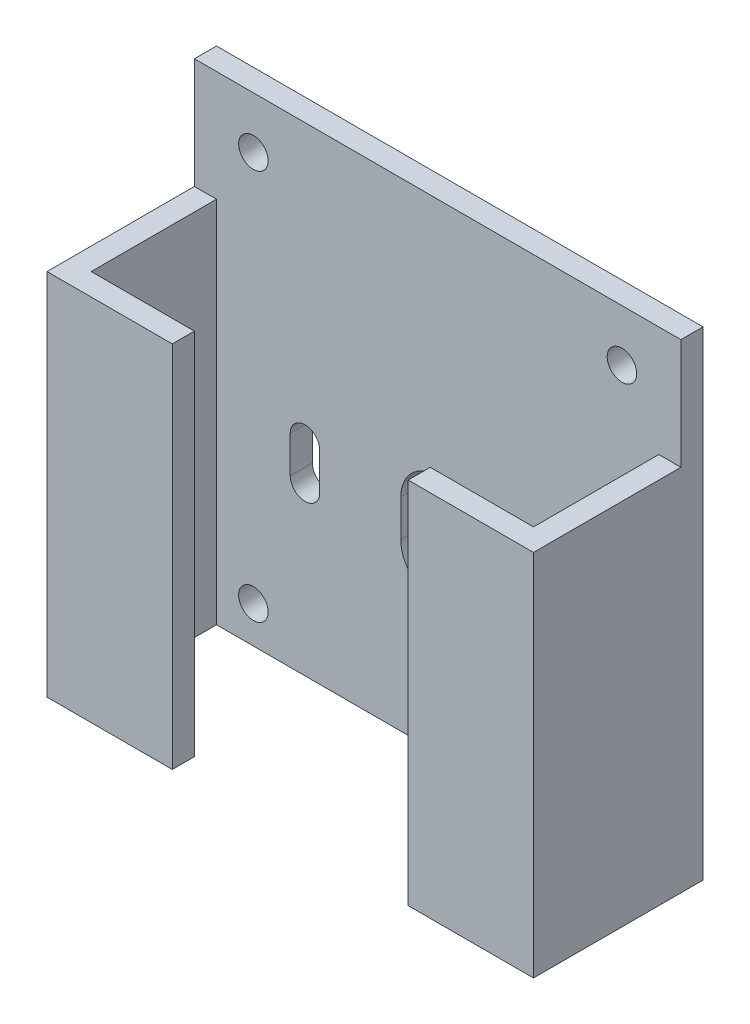
from build123d import *

# Parameters (mm, degrees)
SKETCH1_W           = 23
SKETCH1_H           = 65
BOSS_EXTRUDE1_DEPTH = 66
SKETCH2_W           = 60
SKETCH2_H           = 17
CUT_EXTRUDE1_DEPTH  = 66
CUT_EXTRUDE2_REACH  = 25
SKETCH3_W           = 32
SKETCH3_H           = 65
CUT_EXTRUDE3_REACH  = 25
SKETCH5_R           = 2
SKETCH6_W           = 17
SKETCH6_H           = 15
CUT_EXTRUDE4_DEPTH  = 20


with BuildPart() as part:
    # Sketch1 → Boss-Extrude1 (new body)
    with BuildSketch(Plane(origin=(0, 0, 0), x_dir=(0, 0, -1), z_dir=(1, 0, 0))):
        with Locations((-11.5, -32.5)):
            Rectangle(SKETCH1_W, SKETCH1_H)
    extrude(amount=-BOSS_EXTRUDE1_DEPTH)

    # Sketch2 → Cut-Extrude1 (cut, through all)
    with BuildSketch(Plane(origin=(0, 0, 0), x_dir=(1, 0, 0), z_dir=(0, 1, 0))):
        with Locations((-33, -11.5)):
            Rectangle(SKETCH2_W, SKETCH2_H)
    extrude(amount=-CUT_EXTRUDE1_DEPTH, mode=Mode.SUBTRACT)

    # Sketch3 → Cut-Extrude2 (cut, up to next)
    with BuildSketch(Plane.XY.offset(23), mode=Mode.PRIVATE) as cut_extrude2_sk1:
        with Locations((-33, -32.5)):
            Rectangle(SKETCH3_W, SKETCH3_H)
    cut_extrude2_tool1 = extrude(cut_extrude2_sk1.sketch, amount=-CUT_EXTRUDE2_REACH, mode=Mode.PRIVATE) & part.part
    add(cut_extrude2_tool1.solids().sort_by_distance((-33, -32.5, 23))[0], mode=Mode.SUBTRACT)

    # Sketch5 → Cut-Extrude3 (cut, up to next)
    with BuildSketch(Plane(origin=(0, 0, 0), x_dir=(-1, 0, 0), z_dir=(0, 0, -1)), mode=Mode.PRIVATE) as cut_extrude3_sk1:
        with Locations((8, -7)):
            Circle(SKETCH5_R)
    cut_extrude3_tool1 = extrude(cut_extrude3_sk1.sketch, amount=-CUT_EXTRUDE3_REACH, mode=Mode.PRIVATE) & part.part
    add(cut_extrude3_tool1.solids().sort_by_distance((-8, -7, 0))[0], mode=Mode.SUBTRACT)
    # Sketch5 → Cut-Extrude3 (cut, up to next)
    with BuildSketch(Plane(origin=(0, 0, 0), x_dir=(-1, 0, 0), z_dir=(0, 0, -1)), mode=Mode.PRIVATE) as cut_extrude3_sk2:
        with Locations((58, -7)):
            Circle(SKETCH5_R)
    cut_extrude3_tool2 = extrude(cut_extrude3_sk2.sketch, amount=-CUT_EXTRUDE3_REACH, mode=Mode.PRIVATE) & part.part
    add(cut_extrude3_tool2.solids().sort_by_distance((-58, -7, 0))[0], mode=Mode.SUBTRACT)
    # Sketch5 → Cut-Extrude3 (cut, up to next)
    with BuildSketch(Plane(origin=(0, 0, 0), x_dir=(-1, 0, 0), z_dir=(0, 0, -1)), mode=Mode.PRIVATE) as cut_extrude3_sk3:
        with Locations((8, -60)):
            Circle(SKETCH5_R)
    cut_extrude3_tool3 = extrude(cut_extrude3_sk3.sketch, amount=-CUT_EXTRUDE3_REACH, mode=Mode.PRIVATE) & part.part
    add(cut_extrude3_tool3.solids().sort_by_distance((-8, -60, 0))[0], mode=Mode.SUBTRACT)
    # Sketch5 → Cut-Extrude3 (cut, up to next)
    with BuildSketch(Plane(origin=(0, 0, 0), x_dir=(-1, 0, 0), z_dir=(0, 0, -1)), mode=Mode.PRIVATE) as cut_extrude3_sk4:
        with Locations((58, -60)):
            Circle(SKETCH5_R)
    cut_extrude3_tool4 = extrude(cut_extrude3_sk4.sketch, amount=-CUT_EXTRUDE3_REACH, mode=Mode.PRIVATE) & part.part
    add(cut_extrude3_tool4.solids().sort_by_distance((-58, -60, 0))[0], mode=Mode.SUBTRACT)
    # Sketch5 → Cut-Extrude3 (cut, up to next)
    with BuildSketch(Plane(origin=(0, 0, 0), x_dir=(-1, 0, 0), z_dir=(0, 0, -1)), mode=Mode.PRIVATE) as cut_extrude3_sk5:
        with BuildLine():
            Line((38, -37.5), (38, -42.5))
            ThreePointArc((38, -42.5), (33, -47.5), (28, -42.5))
            Line((28, -42.5), (28, -37.5))
            ThreePointArc((28, -37.5), (33, -32.5), (38, -37.5))
        make_face()
    cut_extrude3_tool5 = extrude(cut_extrude3_sk5.sketch, amount=-CUT_EXTRUDE3_REACH, mode=Mode.PRIVATE) & part.part
    add(cut_extrude3_tool5.solids().sort_by_distance((-33, -40, 0))[0], mode=Mode.SUBTRACT)
    # Sketch5 → Cut-Extrude3 (cut, up to next)
    with BuildSketch(Plane(origin=(0, 0, 0), x_dir=(-1, 0, 0), z_dir=(0, 0, -1)), mode=Mode.PRIVATE) as cut_extrude3_sk6:
        with BuildLine():
            Line((17, -37.5), (17, -42.5))
            ThreePointArc((17, -42.5), (15, -44.5), (13, -42.5))
            Line((13, -42.5), (13, -37.5))
            ThreePointArc((13, -37.5), (15, -35.5), (17, -37.5))
        make_face()
    cut_extrude3_tool6 = extrude(cut_extrude3_sk6.sketch, amount=-CUT_EXTRUDE3_REACH, mode=Mode.PRIVATE) & part.part
    add(cut_extrude3_tool6.solids().sort_by_distance((-15, -40, 0))[0], mode=Mode.SUBTRACT)
    # Sketch5 → Cut-Extrude3 (cut, up to next)
    with BuildSketch(Plane(origin=(0, 0, 0), x_dir=(-1, 0, 0), z_dir=(0, 0, -1)), mode=Mode.PRIVATE) as cut_extrude3_sk7:
        with BuildLine():
            Line((53, -37.5), (53, -42.5))
            ThreePointArc((53, -42.5), (51, -44.5), (49, -42.5))
            Line((49, -42.5), (49, -37.5))
            ThreePointArc((49, -37.5), (51, -35.5), (53, -37.5))
        make_face()
    cut_extrude3_tool7 = extrude(cut_extrude3_sk7.sketch, amount=-CUT_EXTRUDE3_REACH, mode=Mode.PRIVATE) & part.part
    add(cut_extrude3_tool7.solids().sort_by_distance((-51, -40, 0))[0], mode=Mode.SUBTRACT)

    # Sketch6 → Cut-Extrude4 (cut)
    with BuildSketch(Plane.XY.offset(23)):
        with Locations((-57.5, -7.5)):
            Rectangle(SKETCH6_W, SKETCH6_H)
        with Locations((-8.5, -7.5)):
            Rectangle(SKETCH6_W, SKETCH6_H)
    extrude(amount=-CUT_EXTRUDE4_DEPTH, mode=Mode.SUBTRACT)


solid = part.part
